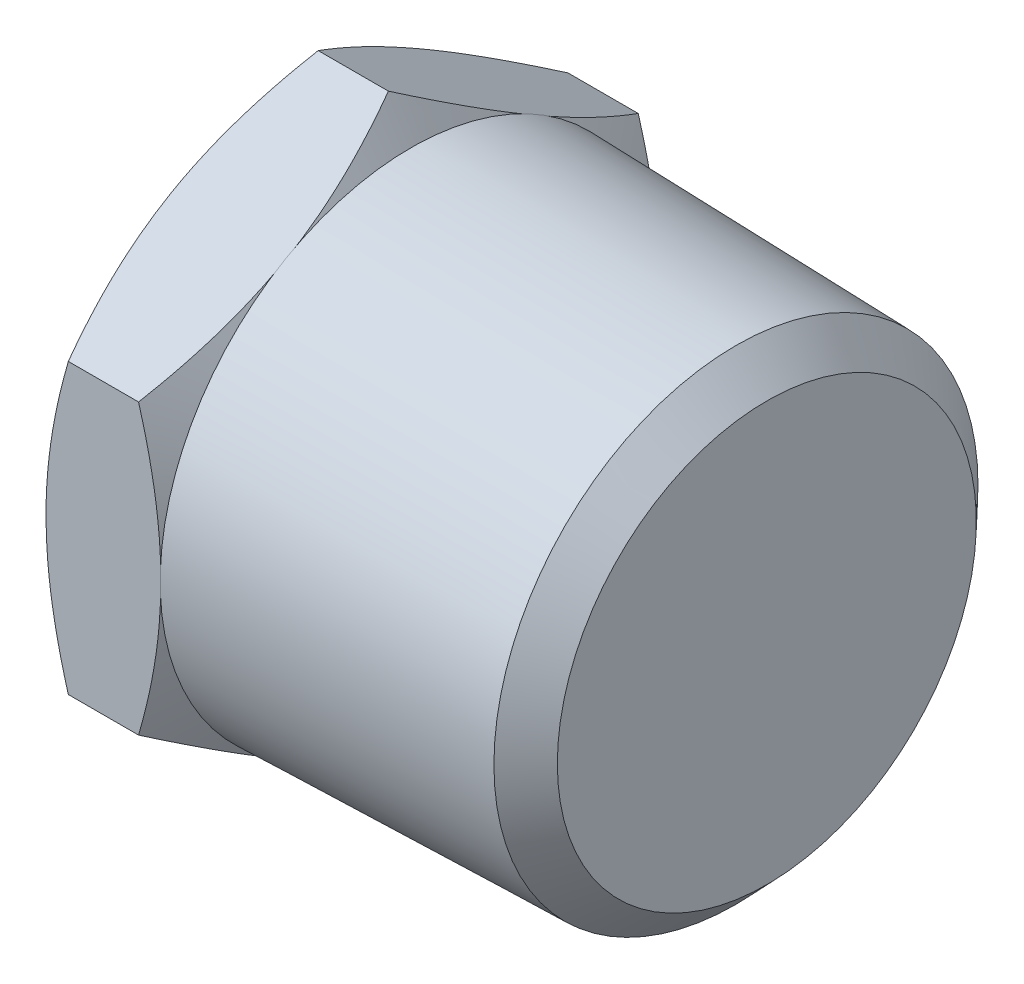
from build123d import *

# Parameters (mm, degrees)
SKETCH2_R          = 10.668
EXTRUDE1_DEPTH     = 15.748
EXTRUDE1_DRAFT     = 1.5
CHAMFER1_SIZE      = 1.366157143
CHAMFER1_SIZE2     = 1.403374095
EXTRUDE2_DEPTH     = 5.08
SKETCH6_R          = 6.858
CUT_EXTRUDE1_DEPTH = 20.983864039
CUT_EXTRUDE1_DRAFT = 1.5
SKETCH12_OUTSIDE_W = 128.474
SKETCH12_OUTSIDE_H = 131.83
SKETCH12_OUTSIDE_R = 11.049
CUT_EXTRUDE6_DEPTH = 27.820778921
CUT_EXTRUDE6_DRAFT = -60
SKETCH13_OUTSIDE_W = 115.58
SKETCH13_OUTSIDE_H = 118.936
SKETCH13_OUTSIDE_R = 11.049
CUT_EXTRUDE7_DEPTH = 24.098660176
CUT_EXTRUDE7_DRAFT = -60


with BuildPart() as part:
    # Sketch2 → Extrude1 (with draft: the straight prism first)
    with BuildSketch(Plane(origin=(10.414, 0, 0), x_dir=(0, 0, -1), z_dir=(1, 0, 0))):
        Circle(SKETCH2_R)
    extrude(amount=-EXTRUDE1_DEPTH)
    # Extrude1: the draft: its side faces are tilted about the plane it starts from
    extrude1_sides = [part.faces().sort_by_distance(p)[0] for p in [
        (2.54, 0, 10.668),
    ]]
    draft(extrude1_sides, Plane(origin=(10.414, 0, 0), x_dir=(0, 0, -1), z_dir=(1, 0, 0)), EXTRUDE1_DRAFT)

    # Chamfer1
    chamfer1_edges = [part.edges().sort_by_distance(p)[0] for p in [
        (10.414, 0, 10.668),
    ]]
    chamfer1_side = [part.faces().sort_by_distance(p)[0] for p in [
        (2.54, 0, 10.874187946),
    ]]
    chamfer(chamfer1_edges, length=CHAMFER1_SIZE, length2=CHAMFER1_SIZE2, reference=chamfer1_side[0])

    # Sketch5 → Extrude2 (add)
    with BuildSketch(Plane.ZY.offset(5.334)):
        Polygon((0, 12.758286249), (-11.049, 6.379143124), (-11.049, -6.379143124), (0, -12.758286249), (11.049, -6.379143124), (11.049, 6.379143124), align=None)
    extrude(amount=EXTRUDE2_DEPTH)


with BuildPart() as cut_extrude1_tool:
    # Sketch6 → Cut-Extrude1 (with draft: the straight prism first)
    with BuildSketch(Plane(origin=(-0.254, 0, 0), x_dir=(0, 0, -1), z_dir=(1, 0, 0))):
        Circle(SKETCH6_R)
    extrude(amount=-CUT_EXTRUDE1_DEPTH)
    # Cut-Extrude1: the draft: its side faces are tilted about the plane it starts from
    cut_extrude1_sides = [cut_extrude1_tool.faces().sort_by_distance(p)[0] for p in [
        (-10.745932019, 0, 6.858),
    ]]
    draft(cut_extrude1_sides, Plane(origin=(-0.254, 0, 0), x_dir=(0, 0, -1), z_dir=(1, 0, 0)), CUT_EXTRUDE1_DRAFT)


with BuildPart() as part_1:
    add(part.part)

    # Cut-Extrude1: cut by cut_extrude1_tool
    add(cut_extrude1_tool.part, mode=Mode.SUBTRACT)


with BuildPart() as cut_extrude6_tool:
    # Sketch12 outside → Cut-Extrude6 (with draft: the straight prism first)
    with BuildSketch(Plane.ZY.offset(10.414)):
        Rectangle(SKETCH12_OUTSIDE_W, SKETCH12_OUTSIDE_H)
        Circle(SKETCH12_OUTSIDE_R, mode=Mode.SUBTRACT)
    extrude(amount=-CUT_EXTRUDE6_DEPTH)
    # Cut-Extrude6: the draft: its side faces are tilted about the plane it starts from
    cut_extrude6_sides = [cut_extrude6_tool.faces().sort_by_distance(p)[0] for p in [
        (3.49638946, -65.915, 0),
        (3.49638946, 0, 64.237),
        (3.49638946, 65.915, 0),
        (3.49638946, 0, -64.237),
        (3.49638946, 0, -11.049),
    ]]
    draft(cut_extrude6_sides, Plane.ZY.offset(10.414), CUT_EXTRUDE6_DRAFT)


with BuildPart() as part_2:
    add(part_1.part)

    # Cut-Extrude6: cut by cut_extrude6_tool
    add(cut_extrude6_tool.part, mode=Mode.SUBTRACT)


with BuildPart() as cut_extrude7_tool:
    # Sketch13 outside → Cut-Extrude7 (with draft: the straight prism first)
    with BuildSketch(Plane(origin=(-5.334, 0, 0), x_dir=(0, 0, -1), z_dir=(1, 0, 0))):
        Rectangle(SKETCH13_OUTSIDE_W, SKETCH13_OUTSIDE_H)
        Circle(SKETCH13_OUTSIDE_R, mode=Mode.SUBTRACT)
    extrude(amount=-CUT_EXTRUDE7_DEPTH)
    # Cut-Extrude7: the draft: its side faces are tilted about the plane it starts from
    cut_extrude7_sides = [cut_extrude7_tool.faces().sort_by_distance(p)[0] for p in [
        (-17.383330088, -59.468, 0),
        (-17.383330088, 0, -57.79),
        (-17.383330088, 59.468, 0),
        (-17.383330088, 0, 57.79),
        (-17.383330088, 0, 11.049),
    ]]
    draft(cut_extrude7_sides, Plane(origin=(-5.334, 0, 0), x_dir=(0, 0, -1), z_dir=(1, 0, 0)), CUT_EXTRUDE7_DRAFT)


with BuildPart() as part_3:
    add(part_2.part)

    # Cut-Extrude7: cut by cut_extrude7_tool
    add(cut_extrude7_tool.part, mode=Mode.SUBTRACT)


solid = part_3.part
